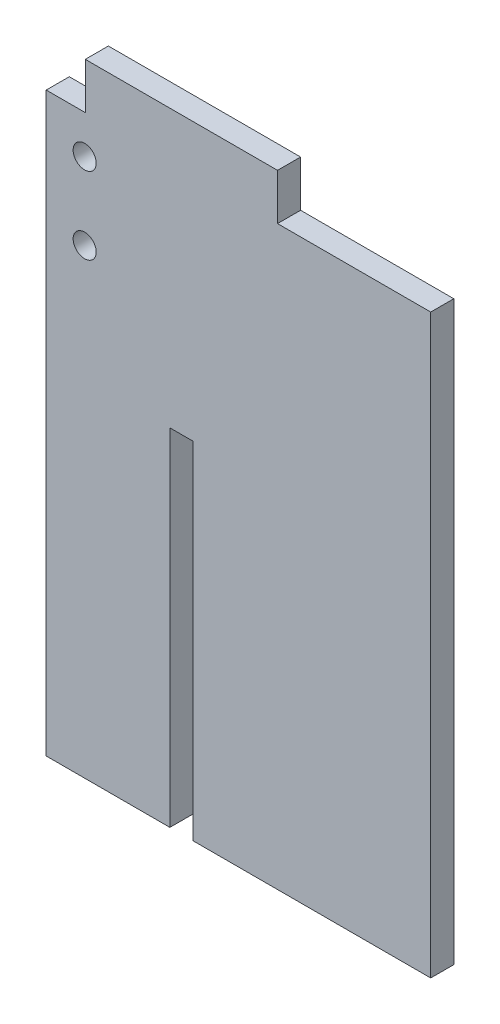
from build123d import *

# Parameters (mm, degrees)
BOSS_EXTRUDE1_DEPTH = 3
SKETCH2_R           = 1.5
CUT_EXTRUDE1_DEPTH  = 4


with BuildPart() as part:
    # Sketch1 → Boss-Extrude1 (new body)
    with BuildSketch(Plane.XY):
        Polygon((12.5, 73.857731997), (-12.5, 73.857731997), (-12.5, 67.857731997), (-17.58, 67.857731997), (-17.58, -7.142268003), (-1.5, -7.142268003), (-1.5, 37.857731997), (1.5, 37.857731997), (1.5, -7.142268003), (32.42, -7.142268003), (32.42, 67.857731997), (12.5, 67.857731997), align=None)
    extrude(amount=BOSS_EXTRUDE1_DEPTH)

    # Sketch2 → Cut-Extrude1 (cut, through all)
    with BuildSketch(Plane.XY.offset(3)):
        with Locations((-12.58, 62.857731997)):
            Circle(SKETCH2_R)
        with Locations((-12.58, 52.857731997)):
            Circle(SKETCH2_R)
    extrude(amount=-CUT_EXTRUDE1_DEPTH, mode=Mode.SUBTRACT)


solid = part.part
